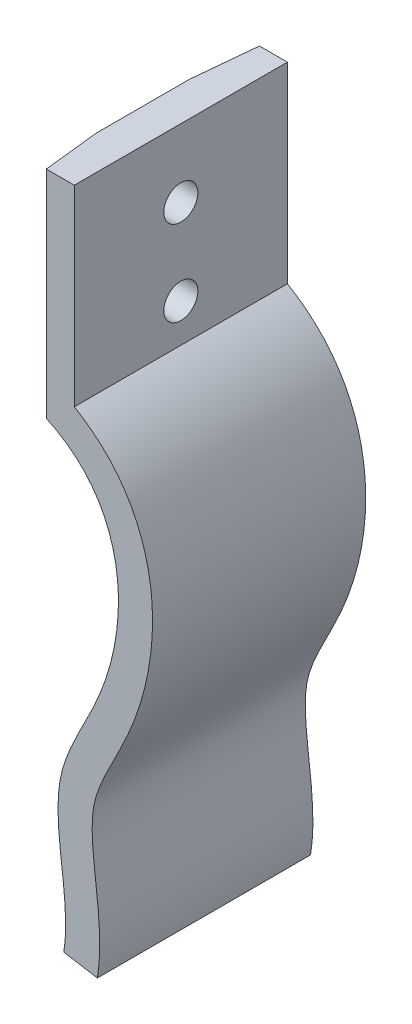
from build123d import *

# Parameters (mm, degrees)
Y_KSEKLIK_EKSTR_ZYON1_DEPTH = 25
IZIM2_R                     = 2
KES_EKSTR_ZYON1_DEPTH       = 25
KES_EKSTR_ZYON2_DEPTH       = 40


with BuildPart() as part:
    # Çizim1 → Yükseklik-Ekstrüzyon1 (new body)
    with BuildSketch(Plane.XY):
        with BuildLine():
            Line((0, 46.809932088), (0, 21.809932088))
            add(Edge.make_bspline(
                [(0, 21.809932088), (10.568682784, 17.485267601), (10.861510075, 0.820586193), (0.998345772, -13.725400391), (2.795894005, -23.640205996), (3.121098113, -29.579949129), (2.768427288, -31.706876061)],
                knots=[0, 0, 0, 0, 0.502231834, 0.695448005, 0.885832632, 1, 1, 1, 1], degree=3))
            Line((2.768427288, -31.706876061), (6.714548286, -32.36119179))
            add(Edge.make_bspline(
                [(4, 24.2963952), (4.685241485, 23.900375179), (6.022043302, 23.011317955), (8.333925315, 20.992557914), (10.609017408, 18.030861677), (12.32636561, 14.066160517), (13.159459329, 9.910750093), (13.24989148, 5.701775618), (12.718641949, 1.530842244), (11.833086969, -1.848590972), (10.899012363, -4.452139312), (9.810416195, -6.984529937), (8.372727065, -9.758751694), (7.204267261, -12.146452944), (6.575072484, -13.855163917), (6.277947315, -15.001021013), (6.121386741, -16.210975711), (6.065175757, -18.048049204), (6.266564263, -20.67501448), (6.722421217, -24.235274395), (7.01194691, -27.479985961), (6.982841835, -30.215107384), (6.831247592, -31.657388466), (6.714548286, -32.36119179)],
                knots=[0.033864542, 0.033864542, 0.033864542, 0.033864542, 0.064056275, 0.094248008, 0.154631474, 0.21501494, 0.275398406, 0.335781873, 0.396165339, 0.456548805, 0.486740538, 0.516932271, 0.577315737, 0.637699203, 0.667890936, 0.698082669, 0.728274402, 0.758466135, 0.818849602, 0.879233068, 0.939616534, 0.969808267, 1, 1, 1, 1], degree=3))
            Line((4, 24.2963952), (4, 46.809932088))
            Line((4, 46.809932088), (0, 46.809932088))
        make_face()
    extrude(amount=Y_KSEKLIK_EKSTR_ZYON1_DEPTH)

    # Çizim2 → Kes-Ekstrüzyon1 (cut)
    with BuildSketch(Plane(origin=(4, 0, 0), x_dir=(0, 0, -1), z_dir=(1, 0, 0))):
        with Locations((-12.5, 38.809932088)):
            Circle(IZIM2_R)
        with Locations((-12.5, 28.809932088)):
            Circle(IZIM2_R)
    extrude(amount=-KES_EKSTR_ZYON1_DEPTH, mode=Mode.SUBTRACT)

    # Çizim3 → Kes-Ekstrüzyon2 (cut)
    with BuildSketch(Plane(origin=(0, 46.809932088, 0), x_dir=(1, 0, 0), z_dir=(0, 1, 0))):
        Polygon((0, 0), (0, -7.486814194), (0.721092404, 0), align=None)
        Polygon((0, -25), (0, -18.429300979), (0.721092404, -25), align=None)
    extrude(amount=-KES_EKSTR_ZYON2_DEPTH, mode=Mode.SUBTRACT)


solid = part.part
